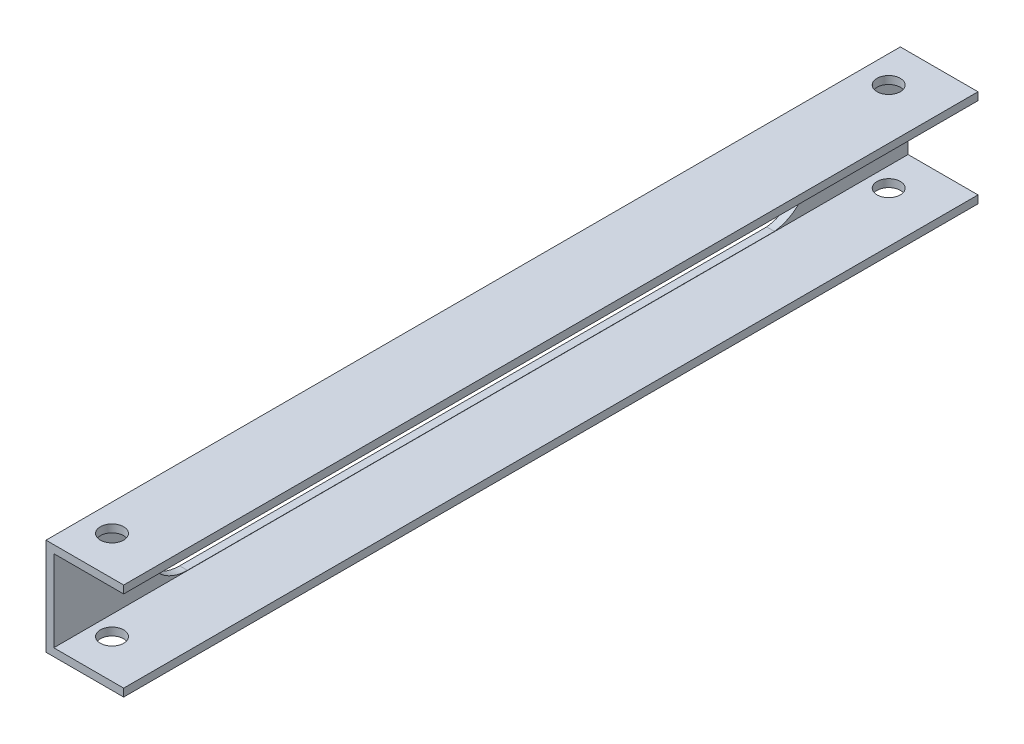
from build123d import *

# Parameters (mm, degrees)
BOSS_EXTRUDE1_DEPTH = 220
CUT_EXTRUDE1_REACH  = 22
SKETCH3_R           = 3
CUT_EXTRUDE2_DEPTH  = 220


with BuildPart() as part:
    # Sketch1 → Boss-Extrude1 (new body)
    with BuildSketch(Plane.XY):
        Polygon((-157.703422053, 227.136882129), (-157.703422053, 225.136882129), (-177.703422053, 225.136882129), (-177.703422053, 250.136882129), (-157.703422053, 250.136882129), (-157.703422053, 248.136882129), (-175.703422053, 248.136882129), (-175.703422053, 227.136882129), align=None)
    extrude(amount=BOSS_EXTRUDE1_DEPTH)

    # Sketch2 → Cut-Extrude1 (cut, up to next)
    with BuildSketch(Plane.ZY.offset(177.703422053), mode=Mode.PRIVATE) as cut_extrude1_sk1:
        with BuildLine():
            Line((34.406705906, 248.069619472), (185.593294094, 248.069619472))
            ThreePointArc((185.593294094, 248.069619472), (196.026031437, 237.636882129), (185.593294094, 227.204144786))
            Line((185.593294094, 227.204144786), (34.406705906, 227.204144786))
            ThreePointArc((34.406705906, 227.204144786), (25.093294094, 237.636882129), (34.406705906, 248.069619472))
        make_face()
    cut_extrude1_tool1 = extrude(cut_extrude1_sk1.sketch, amount=-CUT_EXTRUDE1_REACH, mode=Mode.PRIVATE) & part.part
    add(cut_extrude1_tool1.solids().sort_by_distance((-177.703422, 237.636882, 110.543615))[0], mode=Mode.SUBTRACT)

    # Sketch3 → Cut-Extrude2 (cut)
    with BuildSketch(Plane(origin=(0, 250.136882129, 0), x_dir=(1, 0, 0), z_dir=(0, 1, 0))):
        with Locations((-170.703422053, -210)):
            Circle(SKETCH3_R)
        with Locations((-170.703422053, -10)):
            Circle(SKETCH3_R)
    extrude(amount=-CUT_EXTRUDE2_DEPTH, mode=Mode.SUBTRACT)


solid = part.part
